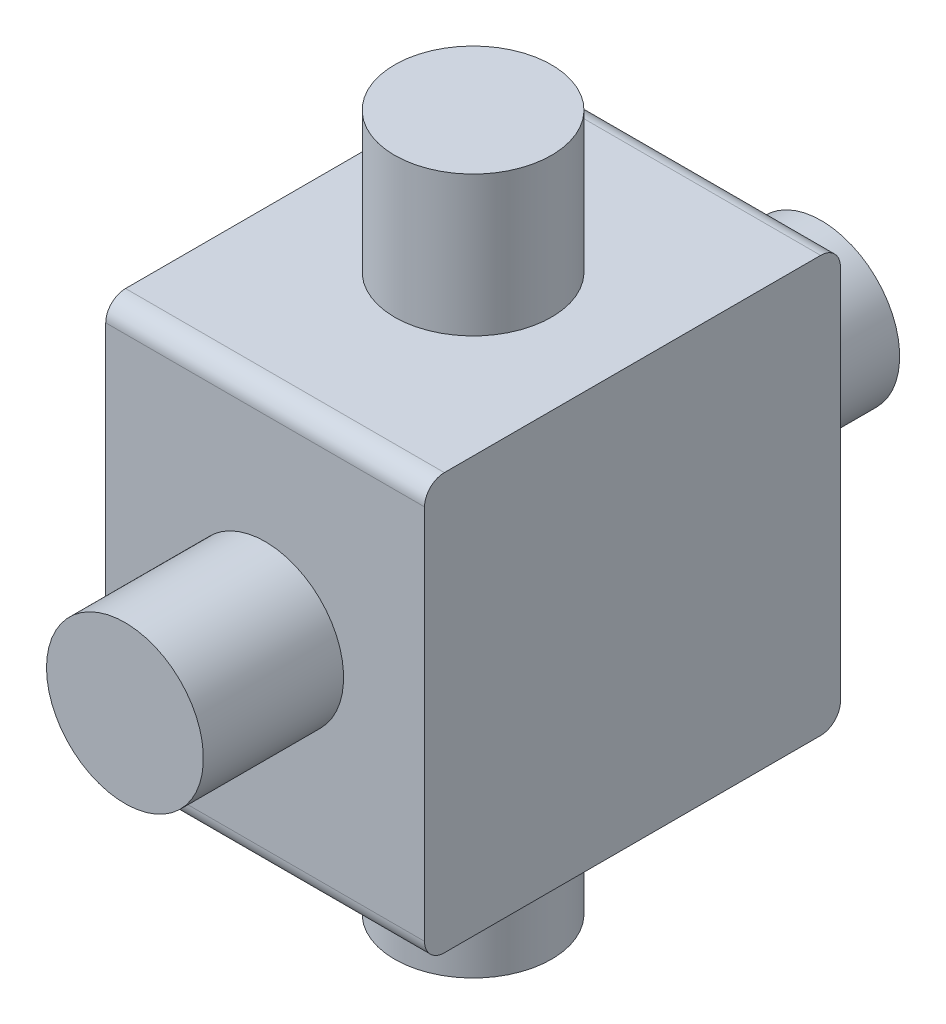
from build123d import *

# Parameters (mm, degrees)
SZKIC1_W                    = 13.2
SZKIC1_H                    = 13.2
DODANIE_WYCI_GNI_CIE1_DEPTH = 10.12
SZKIC2_W                    = 2.49
SZKIC2_H                    = 4.45
SZKIC3_W                    = 2.49
SZKIC3_H                    = 4.45
SZKIC4_W                    = 2.49
SZKIC4_H                    = 4.45
SZKIC5_W                    = 2.49
SZKIC5_H                    = 4.45
ZAOKR_GLENIE1_R             = 0.628571429


with BuildPart() as part:
    # Szkic1 → Dodanie-wyciągnięcie1 (new body)
    with BuildSketch(Plane(origin=(5.06, 0, 0), x_dir=(0, 0, -1), z_dir=(1, 0, 0))):
        Rectangle(SZKIC1_W, SZKIC1_H)
    extrude(amount=-DODANIE_WYCI_GNI_CIE1_DEPTH)

    # Szkic2 → Obrót1 (revolve)
    with BuildSketch(Plane(origin=(0, 0, 0), x_dir=(-1, 0, 0), z_dir=(0, 0, -1))):
        with Locations((-1.245, 8.825)):
            Rectangle(SZKIC2_W, SZKIC2_H)
    revolve(axis=Axis((0, 6.6, 0), (0, 1, 0)))

    # Szkic3 → Obrót2 (revolve)
    with BuildSketch(Plane.XZ):
        with Locations((1.245, -8.825)):
            Rectangle(SZKIC3_W, SZKIC3_H)
    revolve(axis=Axis((0, 0, -6.6), (0, 0, -1)))

    # Szkic4 → Obrót3 (revolve)
    with BuildSketch(Plane(origin=(0, 0, 0), x_dir=(-1, 0, 0), z_dir=(0, 0, -1))):
        with Locations((-1.245, -8.825)):
            Rectangle(SZKIC4_W, SZKIC4_H)
    revolve(axis=Axis((0, -11.05, 0), (0, 1, 0)))

    # Szkic5 → Obrót4 (revolve)
    with BuildSketch(Plane.XZ):
        with Locations((1.245, 8.825)):
            Rectangle(SZKIC5_W, SZKIC5_H)
    revolve(axis=Axis((0, 0, 11.05), (0, 0, -1)))

    # Zaokrąglenie1
    zaokr_glenie1_edges = [part.edges().sort_by_distance(p)[0] for p in [
        (0, 6.6, -6.6),
        (0, -6.6, -6.6),
        (0, -6.6, 6.6),
        (0, 6.6, 6.6),
    ]]
    fillet(zaokr_glenie1_edges, radius=ZAOKR_GLENIE1_R)


solid = part.part
